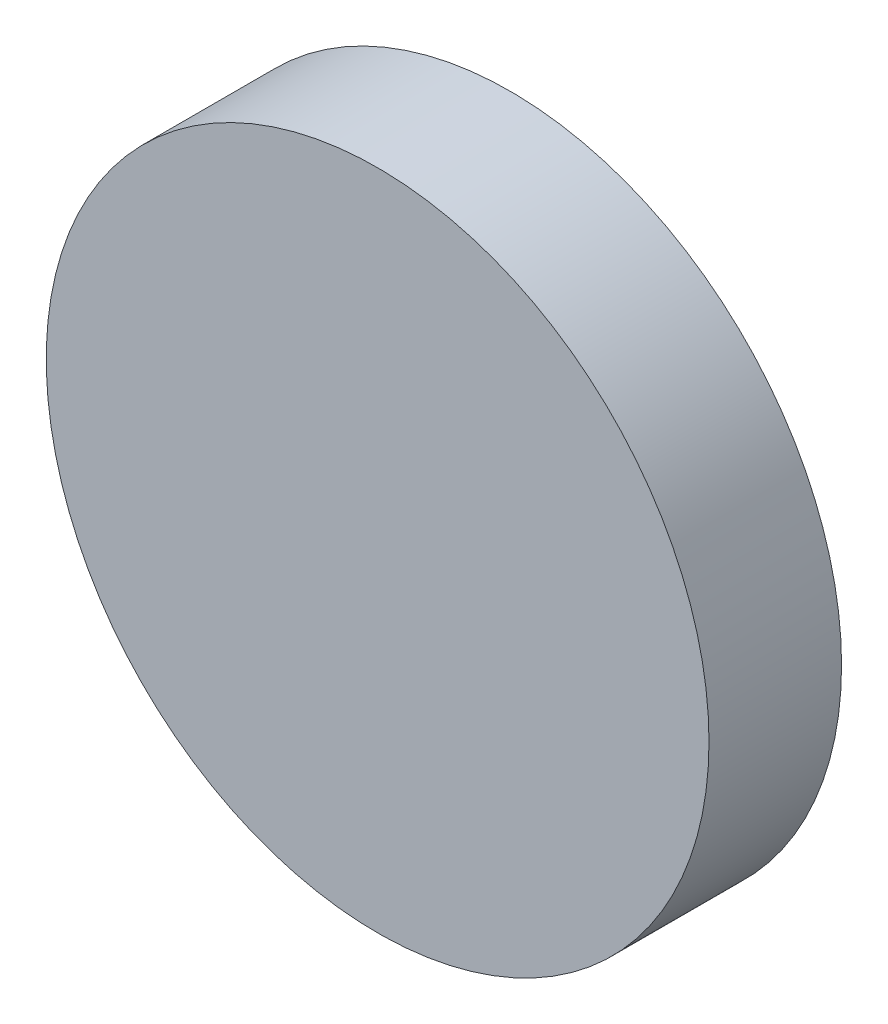
from build123d import *

# Parameters (mm, degrees)
SKETCH1_R           = 2.5
BOSS_EXTRUDE1_DEPTH = 1


with BuildPart() as part:
    # Sketch1 → Boss-Extrude1 (new body)
    with BuildSketch(Plane.XY):
        Circle(SKETCH1_R)
    extrude(amount=BOSS_EXTRUDE1_DEPTH)


solid = part.part
